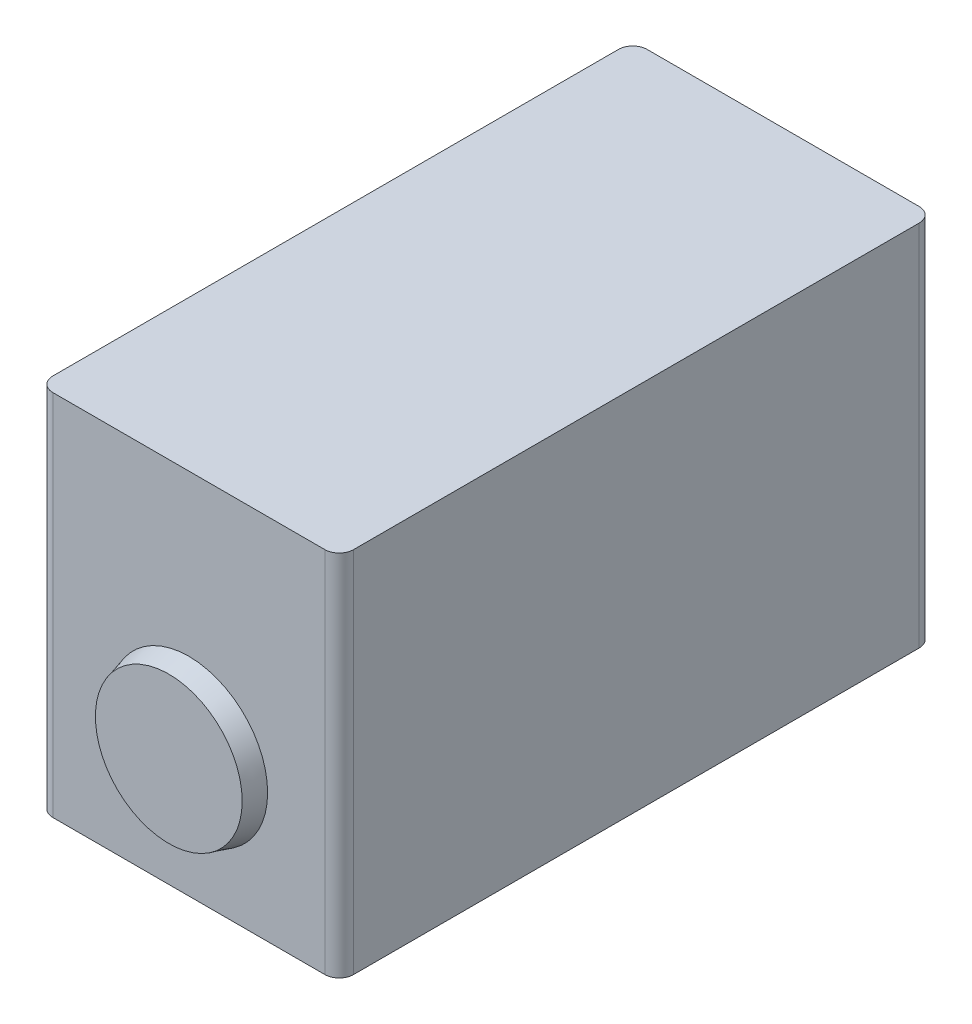
from build123d import *

# Parameters (mm, degrees)
SKETCH1_W           = 21
SKETCH1_H           = 41.5
BOSS_EXTRUDE1_DEPTH = 25.7
FILLET1_R           = 1
SKETCH2_R           = 5.5
BOSS_EXTRUDE2_DEPTH = 1.4
BOSS_EXTRUDE2_TAPER = 15


with BuildPart() as part:
    # Sketch1 → Boss-Extrude1 (new body)
    with BuildSketch(Plane(origin=(0, 0, 0), x_dir=(1, 0, 0), z_dir=(0, 1, 0))):
        Rectangle(SKETCH1_W, SKETCH1_H)
    extrude(amount=BOSS_EXTRUDE1_DEPTH)

    # Fillet1
    fillet1_edges = [part.edges().sort_by_distance(p)[0] for p in [
        (-10.5, 12.85, -20.75),
        (10.5, 12.85, -20.75),
        (10.5, 12.85, 20.75),
        (-10.5, 12.85, 20.75),
    ]]
    fillet(fillet1_edges, radius=FILLET1_R)

    # Sketch2 → Boss-Extrude2 (add)
    with BuildSketch(Plane.XY.offset(20.75)):
        with Locations((0, 9)):
            Circle(SKETCH2_R)
    extrude(amount=BOSS_EXTRUDE2_DEPTH, taper=BOSS_EXTRUDE2_TAPER)


solid = part.part
